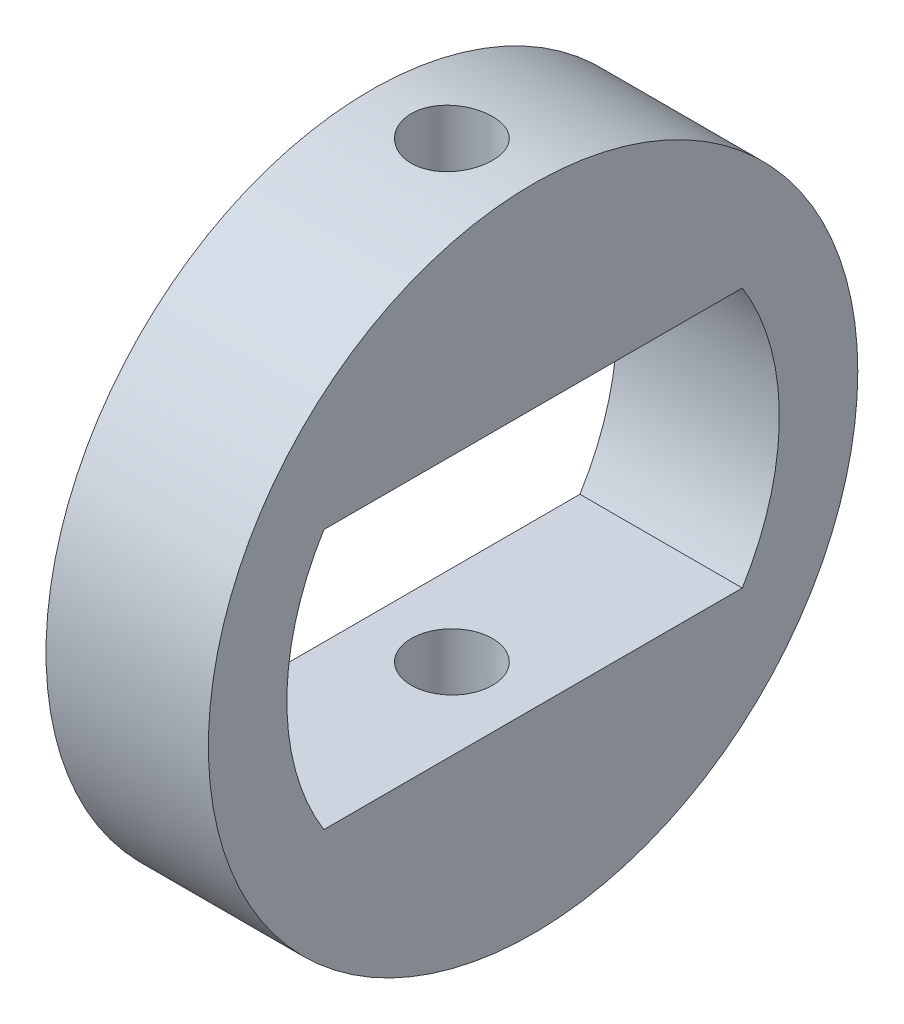
from build123d import *

# Parameters (mm, degrees)
SKETCH1_R               = 6
BOSS_EXTRUDE1_DEPTH     = 3
SKETCH2_R               = 0.75
CUT_EXTRUDE1_DEPTH      = 9.4
CUT_EXTRUDE1_DEPTH_BACK = 4.6


with BuildPart() as part:
    # Sketch1 → Boss-Extrude1 (new body)
    with BuildSketch(Plane(origin=(0, 0, 0), x_dir=(0, 0, -1), z_dir=(1, 0, 0))):
        Circle(SKETCH1_R)
        with BuildLine():
            Line((-3.865553001, 2.4), (3.865553001, 2.4))
            ThreePointArc((3.865553001, 2.4), (4.55, 0), (3.865553001, -2.4))
            Line((3.865553001, -2.4), (-3.865553001, -2.4))
            ThreePointArc((-3.865553001, -2.4), (-4.55, 0), (-3.865553001, 2.4))
        make_face(mode=Mode.SUBTRACT)
    extrude(amount=BOSS_EXTRUDE1_DEPTH)

    # Sketch2 → Cut-Extrude1 (cut, two sides)
    with BuildSketch(Plane(origin=(0, -2.4, 0), x_dir=(1, 0, 0), z_dir=(0, 1, 0))) as cut_extrude1_sk:
        with Locations((1.5, 0)):
            Circle(SKETCH2_R)
    extrude(amount=CUT_EXTRUDE1_DEPTH, mode=Mode.SUBTRACT)
    extrude(cut_extrude1_sk.sketch, amount=-CUT_EXTRUDE1_DEPTH_BACK, mode=Mode.SUBTRACT)


solid = part.part
